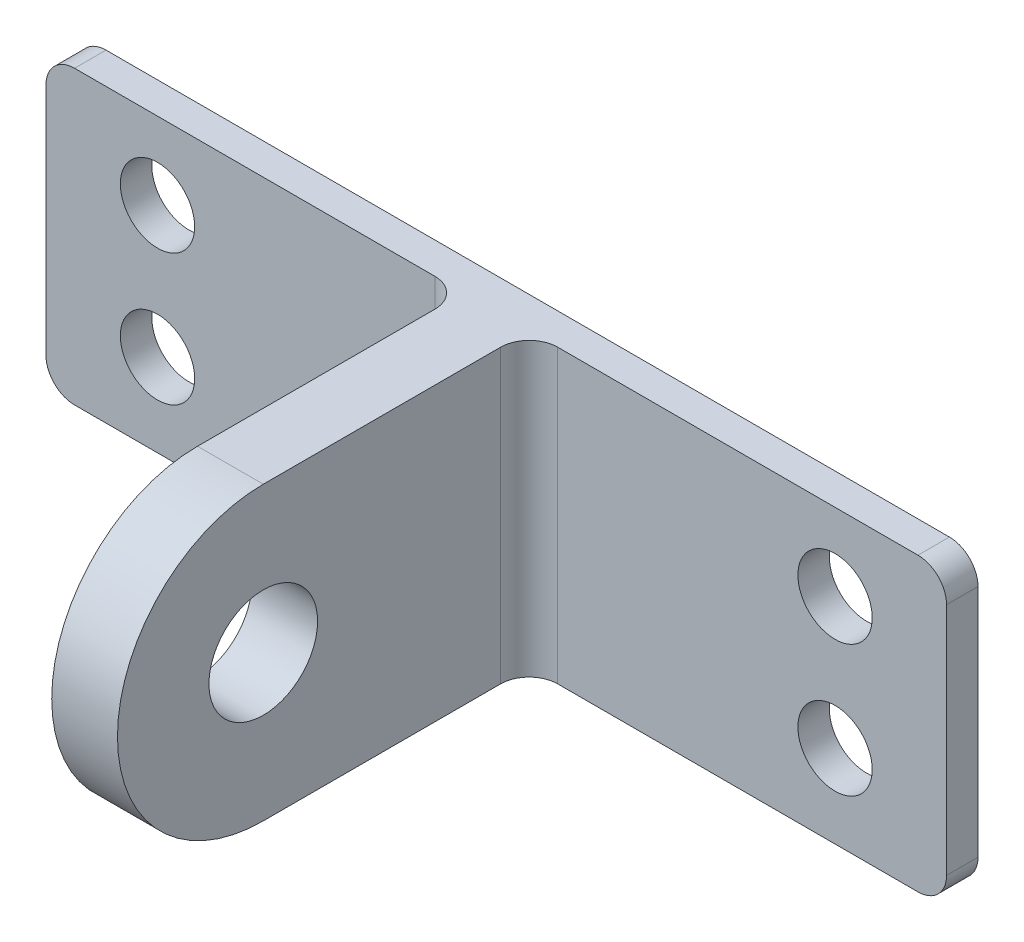
from build123d import *

# Parameters (mm, degrees)
SKETCH1_W             = 37.084
SKETCH1_H             = 25.908
SKETCH1_R             = 3.302
BOSS_EXTRUDE1_DEPTH   = 2.794
BOSS_EXTRUDE1_2_DEPTH = 2.794
SKETCH1_7_W           = 5.842
SKETCH1_7_H           = 25.908
BOSS_EXTRUDE2_DEPTH   = 39.624
FILLET1_R             = 2.54
SKETCH2_R             = 4.826
CUT_EXTRUDE4_DEPTH    = 39.624
CUT_EXTRUDE5_DEPTH    = 39.624
FILLET2_R             = 2.54


with BuildPart() as part:
    # Sketch1 → Boss-Extrude1 (new body)
    with BuildSketch(Plane.XY):
        with Locations((17.593948052, -12.382571429)):
            Rectangle(SKETCH1_W, SKETCH1_H)
        with Locations((8.957948052, -17.970571429)):
            Circle(SKETCH1_R, mode=Mode.SUBTRACT)
        with Locations((8.957948052, -6.286571429)):
            Circle(SKETCH1_R, mode=Mode.SUBTRACT)
    extrude(amount=BOSS_EXTRUDE1_DEPTH)



with BuildPart() as body_2:
    # Sketch1 → Boss-Extrude1 2 (new body)
    with BuildSketch(Plane.XY):
        with Locations((60.519948052, -12.382571429)):
            Rectangle(SKETCH1_W, SKETCH1_H)
        with Locations((69.155948052, -17.970571429)):
            Circle(SKETCH1_R, mode=Mode.SUBTRACT)
        with Locations((69.155948052, -6.286571429)):
            Circle(SKETCH1_R, mode=Mode.SUBTRACT)
    extrude(amount=BOSS_EXTRUDE1_2_DEPTH)


with BuildPart() as part_1:
    add(part.part)

    add(body_2.part)  # Boss-Extrude2 merges body 2
    # Sketch1_7 → Boss-Extrude2 (add)
    with BuildSketch(Plane.XY):
        with Locations((39.056948052, -12.382571429)):
            Rectangle(SKETCH1_7_W, SKETCH1_7_H)
    extrude(amount=BOSS_EXTRUDE2_DEPTH)

    # Fillet1
    fillet1_edges = [part_1.edges().sort_by_distance(p)[0] for p in [
        (79.061948052, 0.571428571, 1.397),
        (79.061948052, -25.336571429, 1.397),
        (-0.948051948, -25.336571429, 1.397),
        (-0.948051948, 0.571428571, 1.397),
    ]]
    fillet(fillet1_edges, radius=FILLET1_R)

    # Sketch2 → Cut-Extrude4 (cut)
    with BuildSketch(Plane(origin=(41.977948052, 0, 0), x_dir=(0, 0, -1), z_dir=(1, 0, 0))):
        with Locations((-26.416, -12.382571429)):
            Circle(SKETCH2_R)
    extrude(amount=-CUT_EXTRUDE4_DEPTH, mode=Mode.SUBTRACT)

    # Sketch2_11 → Cut-Extrude5 (cut)
    with BuildSketch(Plane(origin=(41.977948052, 0, 0), x_dir=(0, 0, -1), z_dir=(1, 0, 0))):
        with BuildLine():
            ThreePointArc((-26.416, -25.336571429), (-39.37, -12.382571429), (-26.416, 0.571428571))
            Line((-26.416, 0.571428571), (-39.624, 0.571428571))
            Line((-39.624, 0.571428571), (-39.624, -25.336571429))
            Line((-39.624, -25.336571429), (-26.416, -25.336571429))
        make_face()
    extrude(amount=-CUT_EXTRUDE5_DEPTH, mode=Mode.SUBTRACT)

    # Fillet2
    fillet2_edges = [part_1.edges().sort_by_distance(p)[0] for p in [
        (36.135948052, -12.382571429, 2.794),
        (41.977948052, -12.382571429, 2.794),
    ]]
    fillet(fillet2_edges, radius=FILLET2_R)


solid = part_1.part
